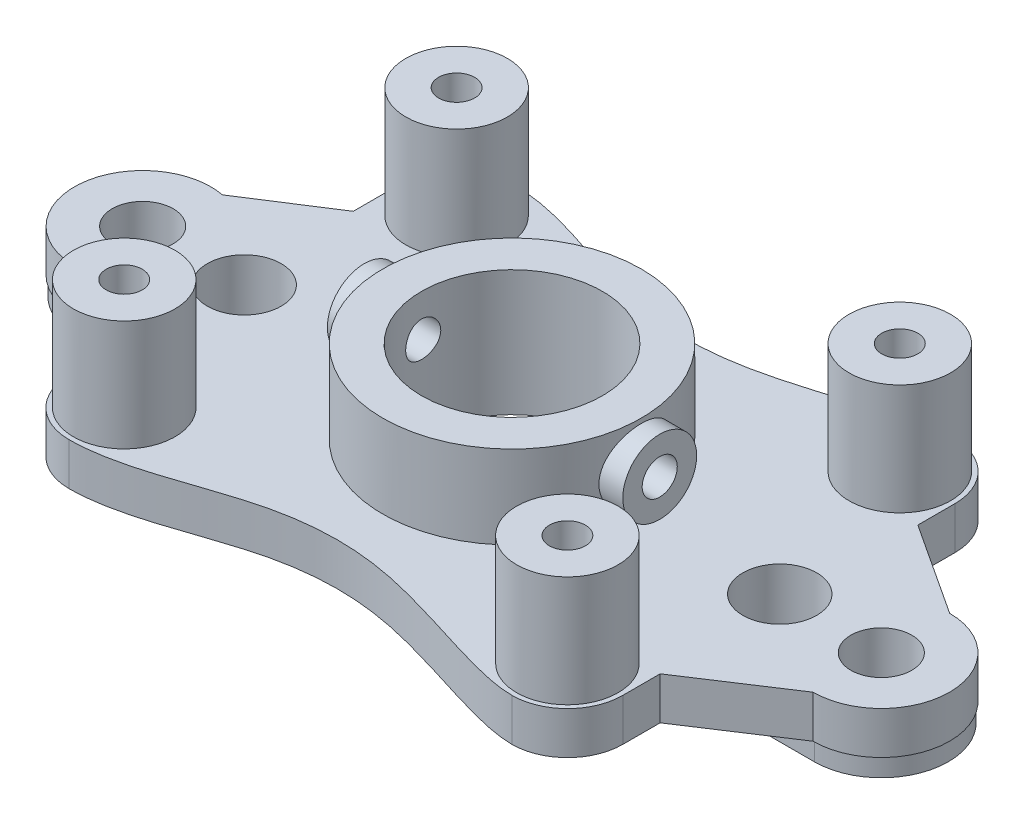
from build123d import *

# Parameters (mm, degrees)
SKETCH1_R           = 4.9
SKETCH1_R_2         = 1.65
BOSS_EXTRUDE1_DEPTH = 2.3
FILLET1_R           = 3
SKETCH3_R           = 2.75
SKETCH3_R_2         = 0.975
BOSS_EXTRUDE2_DEPTH = 6
CUT_EXTRUDE1_DEPTH  = 2.3
SKETCH5_R           = 7
SKETCH5_R_2         = 4.9
BOSS_EXTRUDE3_DEPTH = 4.5
BOSS_EXTRUDE4_START = 6
SKETCH6_R           = 2
BOSS_EXTRUDE4_DEPTH = 2
BOSS_EXTRUDE5_START = -6
SKETCH6_2_R         = 2
BOSS_EXTRUDE5_DEPTH = 2
SKETCH7_R           = 0.104776465
SKETCH7_R_2         = 0.95
CUT_EXTRUDE2_DEPTH  = 16
SKETCH8_R           = 2
CUT_EXTRUDE3_DEPTH  = 2.3
SKETCH10_R          = 2
SKETCH10_R_2        = 1.65
BOSS_EXTRUDE8_DEPTH = 1


with BuildPart() as part:
    # Sketch1 → Boss-Extrude1 (new body)
    with BuildSketch(Plane(origin=(0, 0, 0), x_dir=(1, 0, 0), z_dir=(0, 1, 0))):
        with BuildLine():
            Line((-19.311278394, 3.635335273), (-15, 6.402726073))
            Line((-15, 6.402726073), (-15, 12))
            Line((-15, 12), (15, 12))
            Line((15, 12), (15, 6.97678585))
            Line((15, 6.97678585), (20, 3.7))
            ThreePointArc((20, 3.7), (23.7, 0), (20, -3.7))
            Line((20, -3.7), (15, -6.97678585))
            Line((15, -6.97678585), (15, -12))
            Line((15, -12), (-15, -12))
            Line((-15, -12), (-15, -6.402726073))
            Line((-15, -6.402726073), (-19.311278394, -3.635335273))
            ThreePointArc((-19.311278394, -3.635335273), (-23.7, 0), (-19.311278394, 3.635335273))
        make_face()
        Circle(SKETCH1_R, mode=Mode.SUBTRACT)
        with Locations((-20, 0)):
            Circle(SKETCH1_R_2, mode=Mode.SUBTRACT)
        with Locations((20, 0)):
            Circle(SKETCH1_R_2, mode=Mode.SUBTRACT)
    extrude(amount=BOSS_EXTRUDE1_DEPTH)

    # Fillet1
    fillet1_edges = [part.edges().sort_by_distance(p)[0] for p in [
        (-15, 1.15, -12),
        (15, 1.15, -12),
        (15, 1.15, 12),
        (-15, 1.15, 12),
    ]]
    fillet(fillet1_edges, radius=FILLET1_R)

    # Sketch3 → Boss-Extrude2 (add)
    with BuildSketch(Plane(origin=(0, 2.3, 0), x_dir=(1, 0, 0), z_dir=(0, 1, 0))):
        with Locations((-12, 9)):
            Circle(SKETCH3_R)
        with Locations((-12, 9)):
            Circle(SKETCH3_R_2, mode=Mode.SUBTRACT)
        with Locations((12, 9)):
            Circle(SKETCH3_R)
        with Locations((12, 9)):
            Circle(SKETCH3_R_2, mode=Mode.SUBTRACT)
        with Locations((12, -9)):
            Circle(SKETCH3_R)
        with Locations((12, -9)):
            Circle(SKETCH3_R_2, mode=Mode.SUBTRACT)
        with Locations((-12, -9)):
            Circle(SKETCH3_R)
        with Locations((-12, -9)):
            Circle(SKETCH3_R_2, mode=Mode.SUBTRACT)
    extrude(amount=BOSS_EXTRUDE2_DEPTH)

    # Sketch4 → Cut-Extrude1 (cut)
    with BuildSketch(Plane(origin=(0, 2.3, 0), x_dir=(1, 0, 0), z_dir=(0, 1, 0))):
        with BuildLine():
            Line((-12, 12), (-12, 16.294257714))
            Line((-12, 16.294257714), (12, 16.294257714))
            Line((12, 16.294257714), (12, 15.219911052))
            Line((12, 15.219911052), (12, 12))
            add(Edge.make_bspline(
                [(-12, 12), (-9.057245707, 12), (-4.223972764, 9.428637942), (3.764574149, 9.238075055), (9.81416723, 12), (12, 12)],
                knots=[0, 0, 0, 0, 0.370531455, 0.610499762, 1, 1, 1, 1], degree=3))
        make_face()
        with BuildLine():
            Line((12, -16.294257714), (12, -15.219911052))
            Line((12, -15.219911052), (12, -12))
            add(Edge.make_bspline(
                [(-12, -12), (-9.057245707, -12), (-4.223972764, -9.428637942), (3.764574149, -9.238075055), (9.81416723, -12), (12, -12)],
                knots=[0, 0, 0, 0, 0.370531455, 0.610499762, 1, 1, 1, 1], degree=3))
            Line((-12, -12), (-12, -16.294257714))
            Line((-12, -16.294257714), (12, -16.294257714))
        make_face()
    extrude(amount=-CUT_EXTRUDE1_DEPTH, mode=Mode.SUBTRACT)

    # Sketch5 → Boss-Extrude3 (add)
    with BuildSketch(Plane(origin=(0, 2.3, 0), x_dir=(1, 0, 0), z_dir=(0, 1, 0))):
        Circle(SKETCH5_R)
        Circle(SKETCH5_R_2, mode=Mode.SUBTRACT)
    extrude(amount=BOSS_EXTRUDE3_DEPTH)

    # Sketch6 → Boss-Extrude4 (add)
    with BuildSketch(Plane(origin=(0, 0, 0), x_dir=(0, 0, -1), z_dir=(1, 0, 0)).offset(BOSS_EXTRUDE4_START)):
        with Locations((0, 4.55)):
            Circle(SKETCH6_R)
    extrude(amount=BOSS_EXTRUDE4_DEPTH)

    # Sketch6_2 → Boss-Extrude5 (add)
    with BuildSketch(Plane(origin=(0, 0, 0), x_dir=(0, 0, -1), z_dir=(1, 0, 0)).offset(BOSS_EXTRUDE5_START)):
        with Locations((0, 4.55)):
            Circle(SKETCH6_2_R)
    extrude(amount=-BOSS_EXTRUDE5_DEPTH)

    # Sketch7 → Cut-Extrude2 (cut)
    with BuildSketch(Plane(origin=(8, 0, 0), x_dir=(0, 0, -1), z_dir=(1, 0, 0))):
        with Locations((-18.077789398, 8.361547887)):
            Circle(SKETCH7_R)
        with Locations((0, 4.55)):
            Circle(SKETCH7_R_2)
    extrude(amount=-CUT_EXTRUDE2_DEPTH, mode=Mode.SUBTRACT)

    # Sketch8 → Cut-Extrude3 (cut)
    with BuildSketch(Plane(origin=(0, 2.3, 0), x_dir=(1, 0, 0), z_dir=(0, 1, 0))):
        with Locations((-14.5, 0)):
            Circle(SKETCH8_R)
        with Locations((14.5, 0)):
            Circle(SKETCH8_R)
    extrude(amount=-CUT_EXTRUDE3_DEPTH, mode=Mode.SUBTRACT)

    # Sketch10 → Boss-Extrude8 (add)
    with BuildSketch(Plane.XZ):
        with BuildLine():
            Line((-20, 3.63), (-14.5, 3.63))
            ThreePointArc((-14.5, 3.63), (-10.87, 0), (-14.5, -3.63))
            Line((-14.5, -3.63), (-20, -3.63))
            ThreePointArc((-20, -3.63), (-23.63, 0), (-20, 3.63))
        make_face()
        with Locations((-14.5, 0)):
            Circle(SKETCH10_R, mode=Mode.SUBTRACT)
        with Locations((-20, 0)):
            Circle(SKETCH10_R_2, mode=Mode.SUBTRACT)
        with BuildLine():
            Line((14.5, 3.63), (20, 3.63))
            ThreePointArc((20, 3.63), (23.63, 0), (20, -3.63))
            Line((20, -3.63), (14.5, -3.63))
            ThreePointArc((14.5, -3.63), (10.87, 0), (14.5, 3.63))
        make_face()
        with Locations((14.5, 0)):
            Circle(SKETCH10_R, mode=Mode.SUBTRACT)
        with Locations((20, 0)):
            Circle(SKETCH10_R_2, mode=Mode.SUBTRACT)
    extrude(amount=BOSS_EXTRUDE8_DEPTH)


solid = part.part
